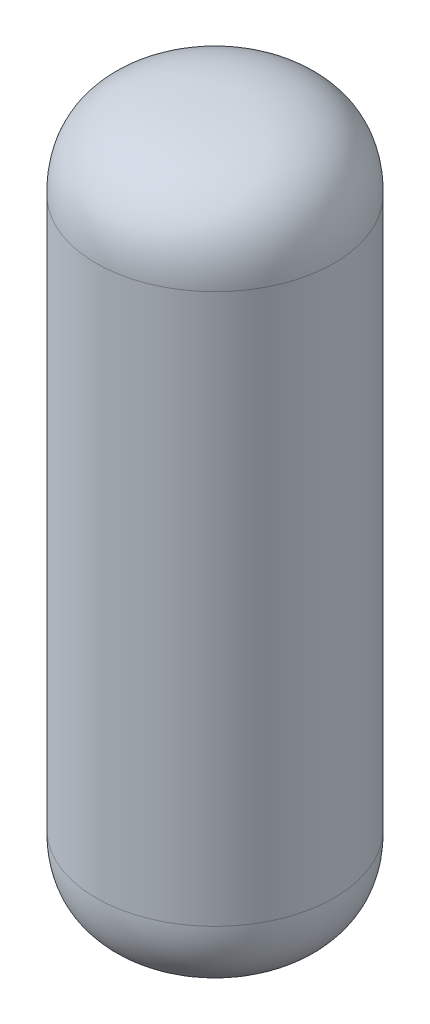
from build123d import *


with BuildPart() as part:
    # Sketch1 → Revolve1 (revolve)
    with BuildSketch(Plane.XY):
        with BuildLine():
            Line((-83.8, 363), (-83.8, 60.381072862))
            add(Edge.make_bspline(
                [(-83.8, 60.381072862), (-84.578755981, -1.395730518), (0, 0)],
                knots=[0, 0, 0, 1, 1, 1], degree=2))
            Line((0, 0), (0, 2.823337447))
            add(Edge.make_bspline(
                [(-78.571627889, 84.98711746), (-81.609028281, 48.944497672), (-76.621547698, 6.710925493), (0, 2.823337447)],
                knots=[0, 0, 0, 0, 1, 1, 1, 1], degree=3))
            Line((-78.571627889, 84.98711746), (-78.571627889, 363))
            Line((-78.571627889, 363), (-78.571627889, 398.01288254))
            Line((-78.571627889, 398.01288254), (-78.571627889, 423.01288254))
            add(Edge.make_bspline(
                [(-78.571627889, 423.01288254), (-81.609028281, 459.055502328), (-76.621547698, 501.289074507), (0, 505.176662553)],
                knots=[0, 0, 0, 0, 1, 1, 1, 1], degree=3))
            Line((0, 505.176662553), (0, 508))
            add(Edge.make_bspline(
                [(-83.8, 447.618927138), (-84.578755981, 509.395730518), (0, 508)],
                knots=[0, 0, 0, 1, 1, 1], degree=2))
            Line((-83.8, 447.618927138), (-83.8, 422.618927138))
            Line((-83.8, 422.618927138), (-83.8, 363))
        make_face()
    revolve(axis=Axis((0, 0, 0), (0, 1, 0)))


solid = part.part
